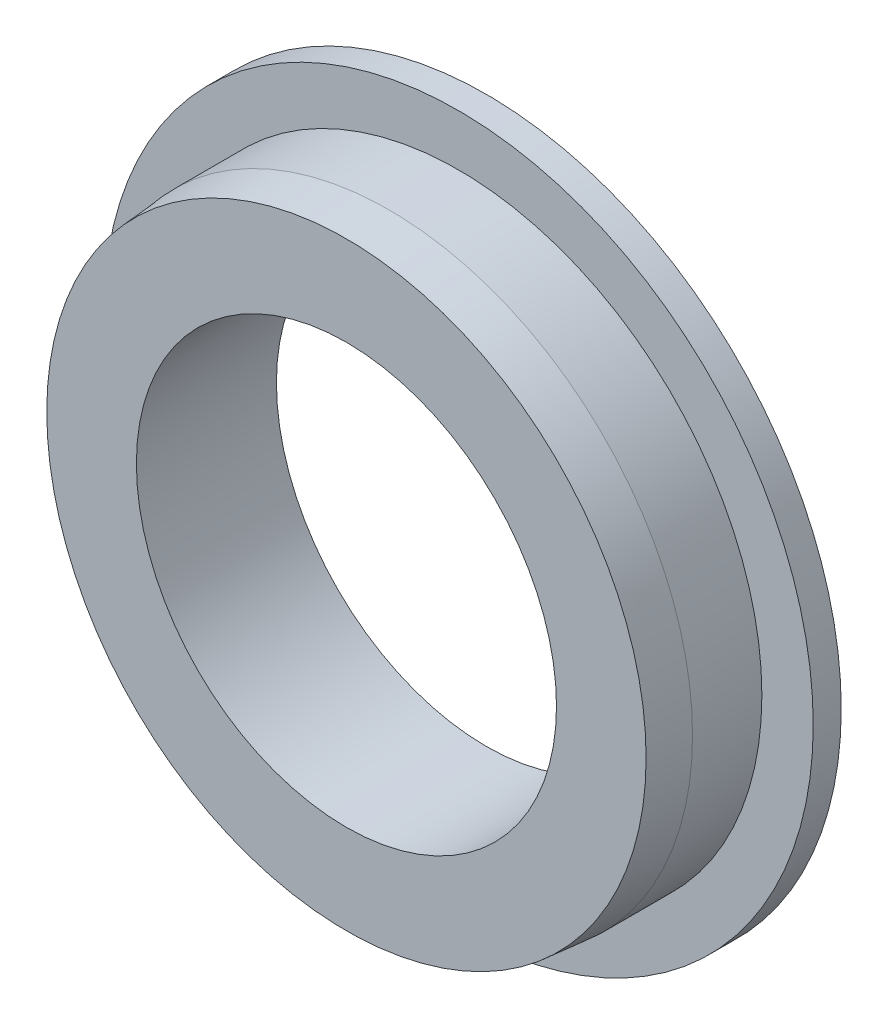
from build123d import *

# Parameters (mm, degrees)
SKETCH1_R           = 24.13
BOSS_EXTRUDE1_DEPTH = 0.9525
SKETCH2_R           = 20.6375
BOSS_EXTRUDE2_DEPTH = 7.62
SKETCH4_R           = 14.2875
CUT_EXTRUDE1_DEPTH  = 10.525
CHAMFER1_SIZE       = 0.254
CHAMFER1_SIZE2      = 2.903233285


with BuildPart() as part:
    # Sketch1 → Boss-Extrude1 (new body, symmetric)
    with BuildSketch(Plane.XY):
        Circle(SKETCH1_R)
    extrude(amount=BOSS_EXTRUDE1_DEPTH, both=True)

    # Sketch2 → Boss-Extrude2 (add)
    with BuildSketch(Plane.XY.offset(0.9525)):
        Circle(SKETCH2_R)
    extrude(amount=BOSS_EXTRUDE2_DEPTH)

    # Sketch4 → Cut-Extrude1 (cut, through all)
    with BuildSketch(Plane(origin=(0, 0, -0.9525), x_dir=(-1, 0, 0), z_dir=(0, 0, -1))):
        Circle(SKETCH4_R)
    extrude(amount=-CUT_EXTRUDE1_DEPTH, mode=Mode.SUBTRACT)

    # Chamfer1
    chamfer1_edges = [part.edges().sort_by_distance(p)[0] for p in [
        (-20.6375, 0, 8.5725),
    ]]
    chamfer1_side = [part.faces().sort_by_distance(p)[0] for p in [
        (-20.053783352, 0, 8.5725),
    ]]
    chamfer(chamfer1_edges, length=CHAMFER1_SIZE, length2=CHAMFER1_SIZE2, reference=chamfer1_side[0])


solid = part.part
